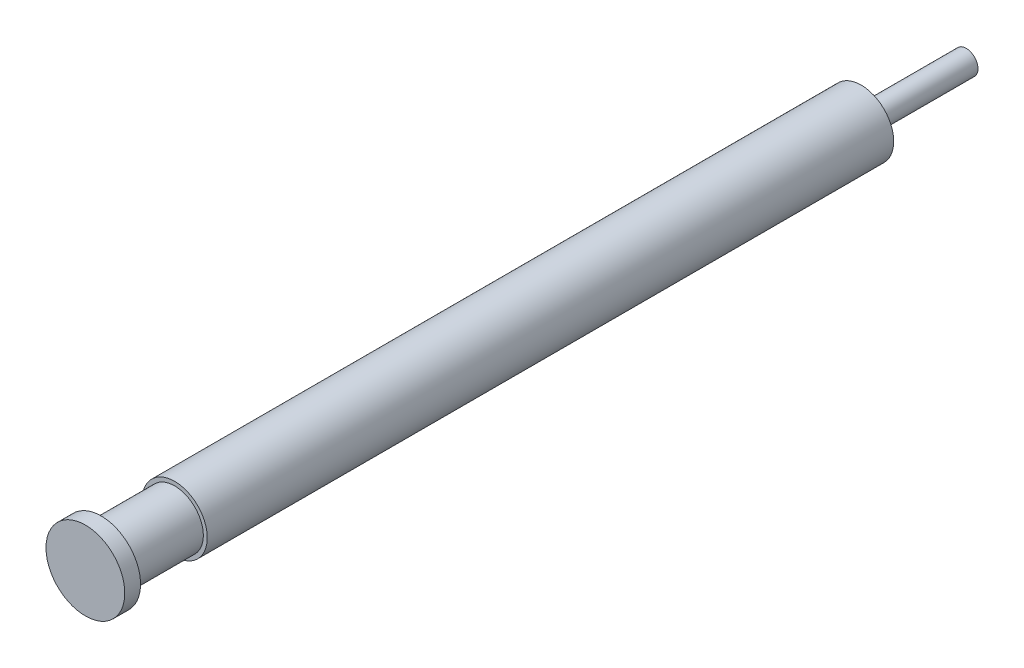
from build123d import *


with BuildPart() as part:
    # Sketch2 → Revolve4 (revolve)
    with BuildSketch(Plane(origin=(0, 0, 0), x_dir=(1, 0, 0), z_dir=(0, 1, 0))):
        Polygon((24.868249983, 17.00561082), (24.868249983, -55.99438918), (28.618249983, -55.99438918), (28.618249983, -54.49438918), (27.593249983, -54.49438918), (27.593249983, -47.49438918), (27.968249983, -47.49438918), (27.968249983, 17.8475545), (25.993249983, 17.8475545), (25.993249983, 27.8475545), (24.868249983, 27.8475545), align=None)
    revolve(axis=Axis((24.868249983, 0, -17.00561082), (0, 0, 1)))


solid = part.part
